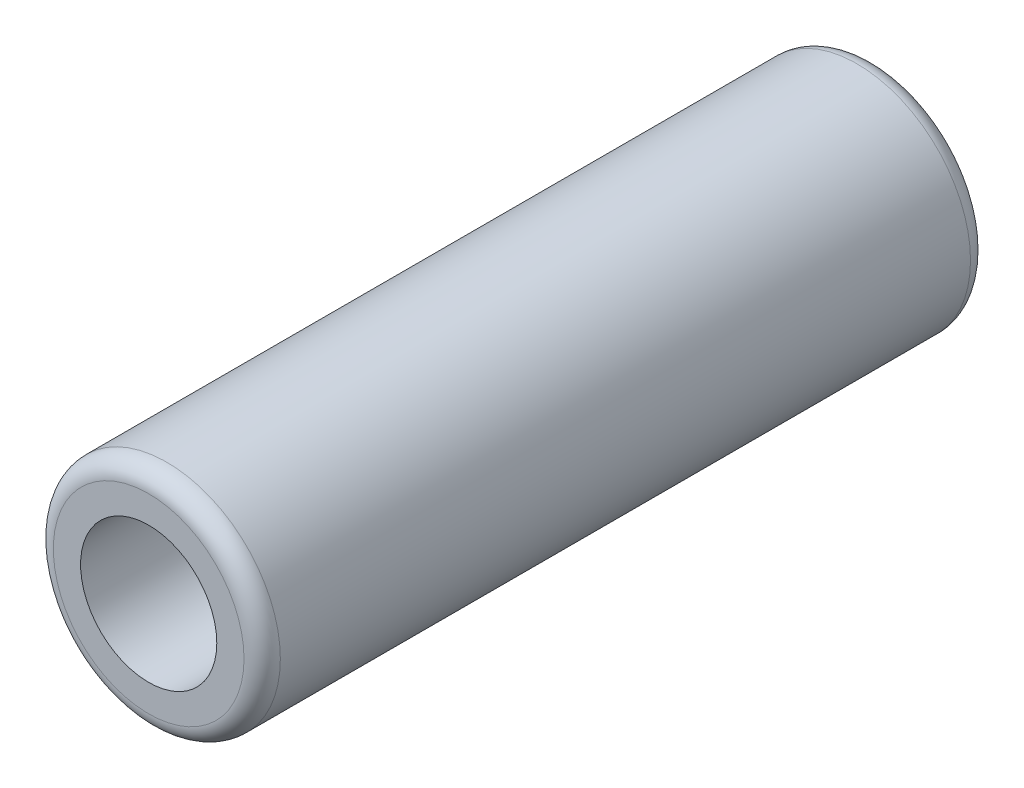
from build123d import *

# Parameters (mm, degrees)
SKETCH1_R           = 62.5
SKETCH1_R_2         = 37.5
BOSS_EXTRUDE1_DEPTH = 200
FILLET1_R           = 10


with BuildPart() as part:
    # Sketch1 → Boss-Extrude1 (new body, symmetric)
    with BuildSketch(Plane.XY):
        Circle(SKETCH1_R)
        Circle(SKETCH1_R_2, mode=Mode.SUBTRACT)
    extrude(amount=BOSS_EXTRUDE1_DEPTH, both=True)

    # Fillet1
    fillet1_edges = [part.edges().sort_by_distance(p)[0] for p in [
        (-62.5, 0, -200),
        (-62.5, 0, 200),
    ]]
    fillet(fillet1_edges, radius=FILLET1_R)


solid = part.part
